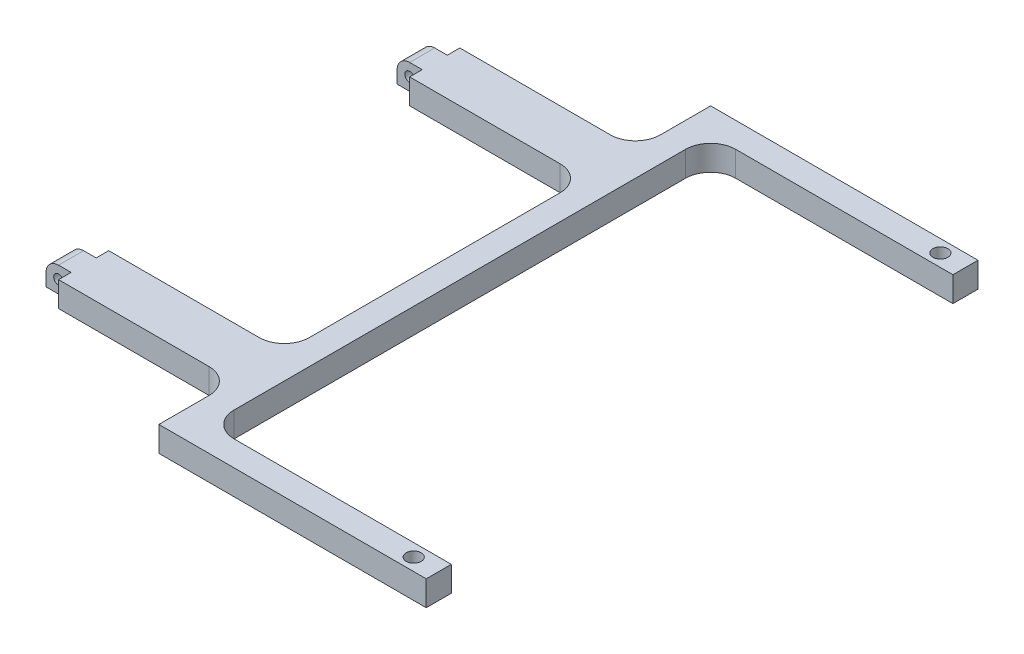
from build123d import *

# Parameters (mm, degrees)
SKETCH1_W                 = 112.141
SKETCH1_H                 = 139.7
EXTRUDE1_DEPTH            = 6.35
SKETCH2_W                 = 44.45
SKETCH2_H                 = 19.05
SKETCH2_W_2               = 61.341
SKETCH2_H_2               = 127
SKETCH2_H_3               = 76.2
CUT_EXTRUDE1_DEPTH        = 6.35
FILLET1_R                 = 6.35
SKETCH5_W                 = 6.35
SKETCH5_H                 = 6.35
EXTRUDE2_DEPTH            = 6.35
FILLET2_R                 = 3.175
F_6_CLEARANCE_HOLE1_D     = 3.7973
F_6_CLEARANCE_HOLE1_DEPTH = 12.7
F_6_CLEARANCE_HOLE1_TIP   = 1.140824014
F_2_CLEARANCE_HOLE1_D     = 2.4384


with BuildPart() as part:
    # Sketch1 → Extrude1 (new body)
    with BuildSketch(Plane(origin=(0, 0, 0), x_dir=(1, 0, 0), z_dir=(0, 1, 0))):
        Rectangle(SKETCH1_W, SKETCH1_H)
    extrude(amount=EXTRUDE1_DEPTH)

    # Sketch2 → Cut-Extrude1 (cut)
    with BuildSketch(Plane(origin=(0, 6.35, 0), x_dir=(-1, 0, 0), z_dir=(0, 1, 0))):
        with Locations((33.8455, -60.325)):
            Rectangle(SKETCH2_W, SKETCH2_H)
        with Locations((33.8455, 60.325)):
            Rectangle(SKETCH2_W, SKETCH2_H)
        with Locations((-25.4, 0)):
            Rectangle(SKETCH2_W_2, SKETCH2_H_2)
        with Locations((33.8455, 0)):
            Rectangle(SKETCH2_W, SKETCH2_H_3)
    extrude(amount=-CUT_EXTRUDE1_DEPTH, mode=Mode.SUBTRACT)

    # Fillet1
    fillet1_edges = [part.edges().sort_by_distance(p)[0] for p in [
        (-11.6205, 3.175, -50.8),
        (-11.6205, 3.175, 50.8),
        (-5.2705, 3.175, 63.5),
        (-5.2705, 3.175, -63.5),
        (-11.6205, 3.175, -38.1),
        (-11.6205, 3.175, 38.1),
    ]]
    fillet(fillet1_edges, radius=FILLET1_R)

    # Sketch5 → Extrude2 (add)
    with BuildSketch(Plane.ZY.offset(56.0705)):
        with Locations((44.45, 3.175)):
            Rectangle(SKETCH5_W, SKETCH5_H)
        with Locations((-44.45, 3.175)):
            Rectangle(SKETCH5_W, SKETCH5_H)
    extrude(amount=EXTRUDE2_DEPTH)

    # Fillet2
    fillet2_edges = [part.edges().sort_by_distance(p)[0] for p in [
        (-62.4205, 6.35, 44.45),
        (-62.4205, 6.35, -44.45),
    ]]
    fillet(fillet2_edges, radius=FILLET2_R)

    # #6 Clearance Hole1
    with Locations(Plane(origin=(49.7205, 0, 66.675), x_dir=(0, 0, -1), z_dir=(0, -1, 0))):
        with Locations((0, 0), (133.35, 0)):
            Hole(F_6_CLEARANCE_HOLE1_D / 2, depth=F_6_CLEARANCE_HOLE1_DEPTH)
            with Locations((0, 0, -(F_6_CLEARANCE_HOLE1_DEPTH + F_6_CLEARANCE_HOLE1_TIP / 2))):  # 118° drill point
                Cone(0, F_6_CLEARANCE_HOLE1_D / 2, F_6_CLEARANCE_HOLE1_TIP, mode=Mode.SUBTRACT)

    # #2 Clearance Hole1 (through all)
    with Locations(Plane(origin=(-59.2455, 3.175, 47.625), x_dir=(1, 0, 0), z_dir=(0, 0, 1))):
        with Locations((0, 0)):
            Hole(F_2_CLEARANCE_HOLE1_D / 2)


solid = part.part
